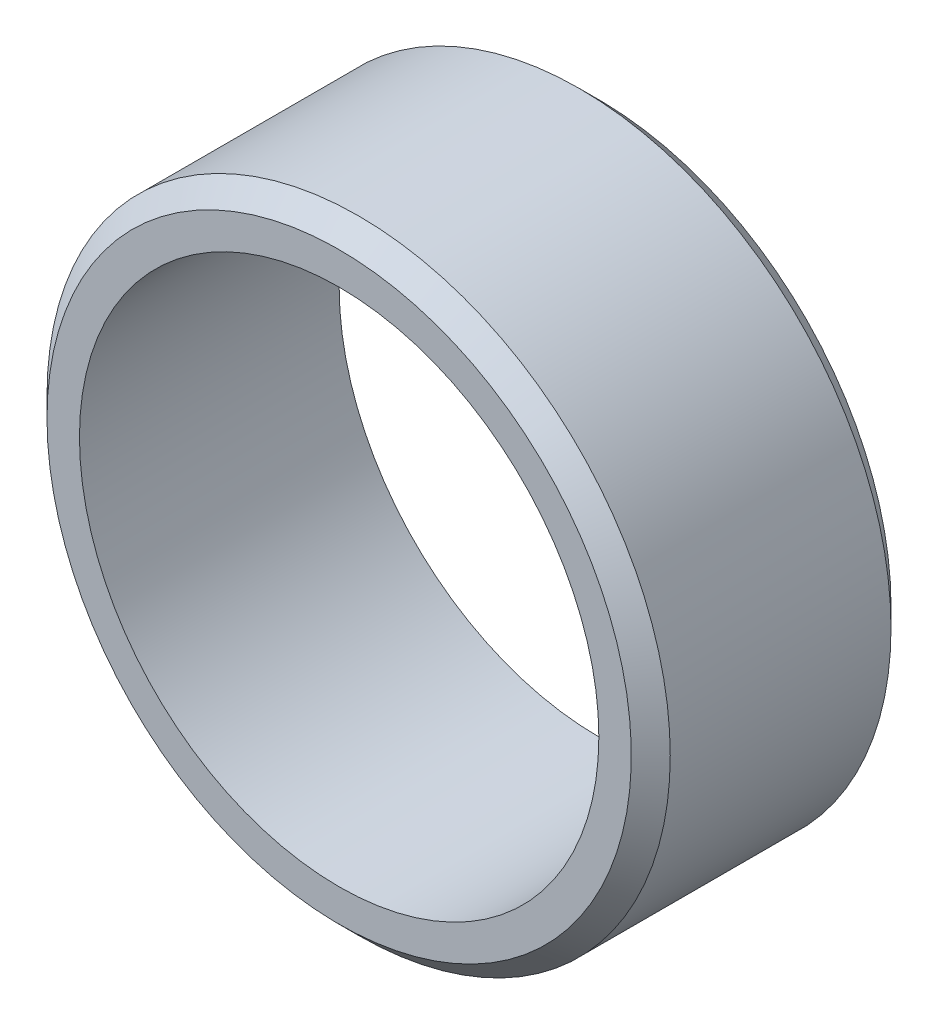
from build123d import *

# Parameters (mm, degrees)
SKETCH3_W     = 25
SKETCH3_H     = 5
CHAMFER1_SIZE = 1.875


with BuildPart() as part:
    # Sketch3 → Revolve1 (revolve)
    with BuildSketch(Plane(origin=(0, 0, 0), x_dir=(0, 0, -1), z_dir=(1, 0, 0))):
        with Locations((0, 27.5)):
            Rectangle(SKETCH3_W, SKETCH3_H)
    revolve(axis=Axis((0, 0, 12.5), (0, 0, -1)))

    # Chamfer1
    chamfer1_edges = [part.edges().sort_by_distance(p)[0] for p in [
        (0, -30, 12.5),
        (0, -30, -12.5),
    ]]
    chamfer(chamfer1_edges, length=CHAMFER1_SIZE)


solid = part.part
